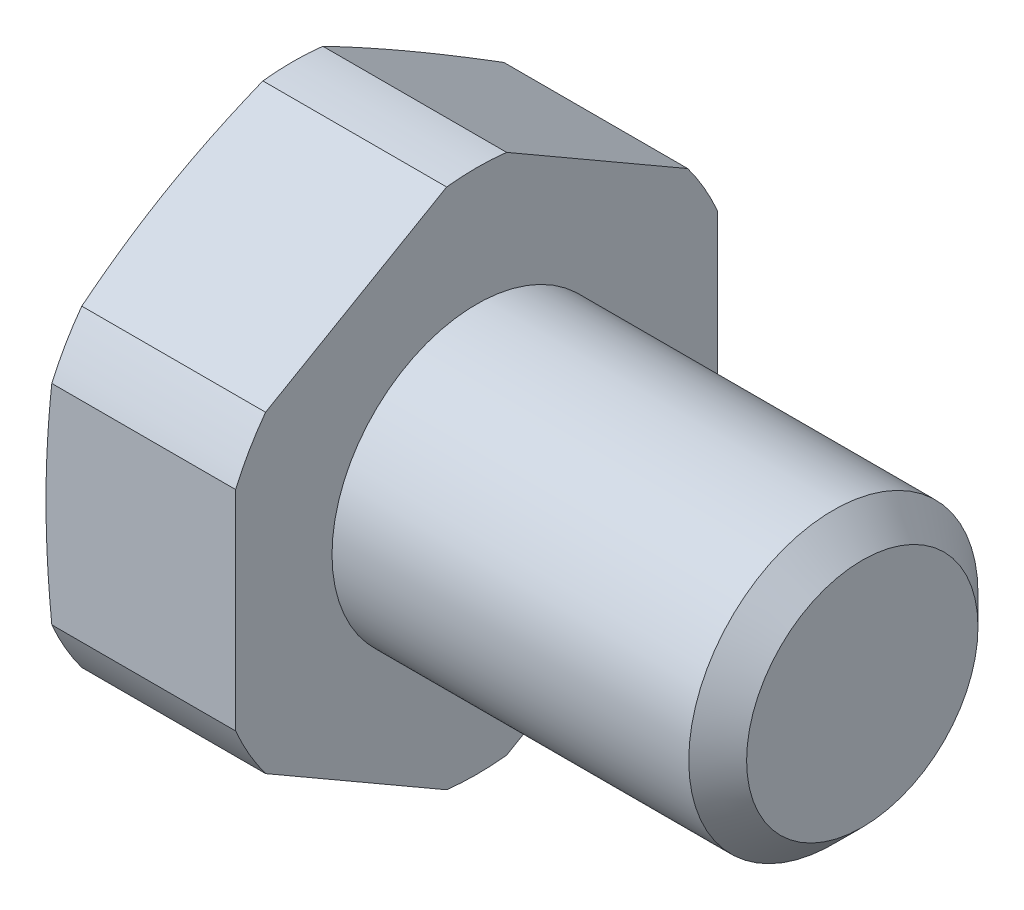
from build123d import *

# Parameters (mm, degrees)
SKETCH_2_OUTSIDE_W  = 16.808
SKETCH_2_OUTSIDE_H  = 16.808
CUT_EXTRUDE_1_DEPTH = 12


with BuildPart() as part:
    # Эскиз1 → Повернуть1 (revolve)
    with BuildSketch(Plane.XY):
        Polygon((-4, 0), (-4, 4.75), (-3.812435565, 5.45), (0, 5.45), (0, 3), (7.4, 3), (8, 2.4), (8, 0), align=None)
    revolve(axis=Axis((-1000, 0, 0), (1, 0, 0)))

    # Эскиз2 outside → Вырез-Вытянуть1 (cut)
    with BuildSketch(Plane.ZY.offset(4)):
        Rectangle(SKETCH_2_OUTSIDE_W, SKETCH_2_OUTSIDE_H)
        Polygon((0, 5.773502692), (-5, 2.886751346), (-5, -2.886751346), (0, -5.773502692), (5, -2.886751346), (5, 2.886751346), align=None, mode=Mode.SUBTRACT)
    extrude(amount=-CUT_EXTRUDE_1_DEPTH, mode=Mode.SUBTRACT)


solid = part.part
